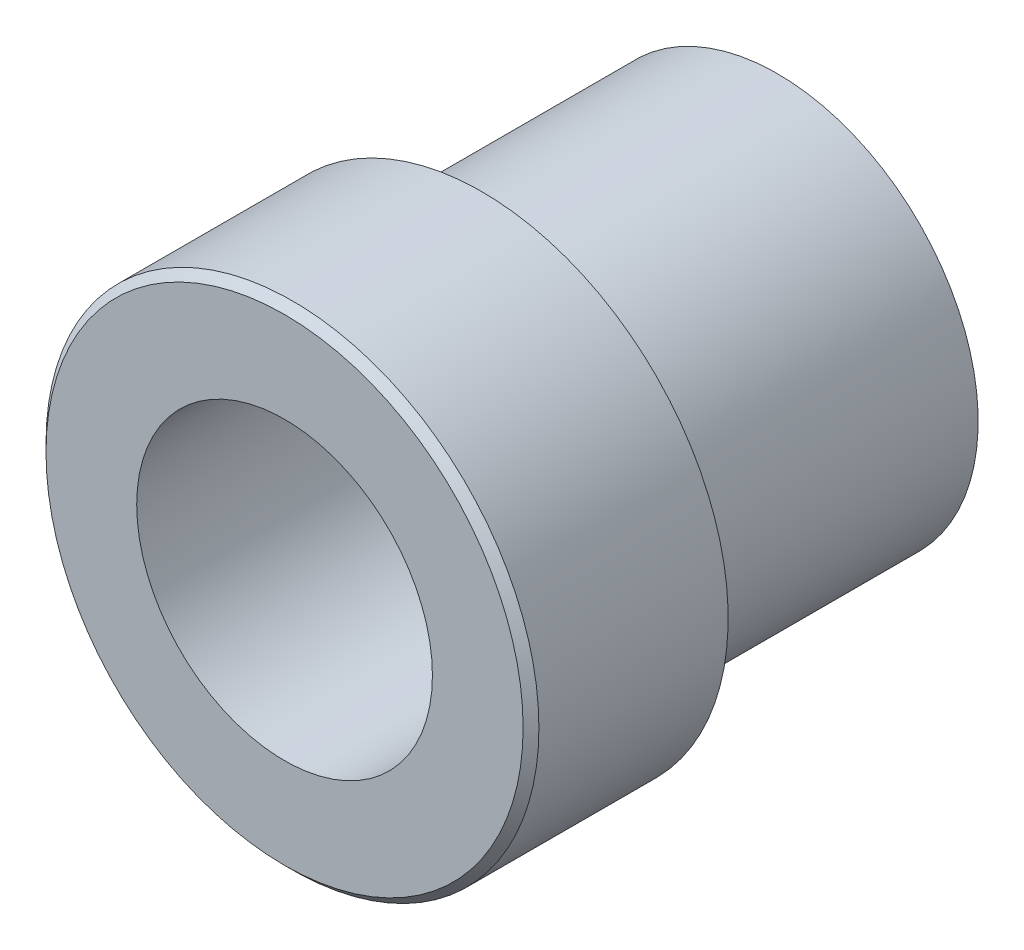
from build123d import *

# Parameters (mm, degrees)
SKETCH1_R                   = 7.9375
BOSS_EXTRUDE1_DEPTH         = 15.875
CHAMFER1_SIZE               = 0.254
SKETCH2_OUTSIDE_W           = 23.376
SKETCH2_OUTSIDE_H           = 23.376
SKETCH2_OUTSIDE_R           = 6.4643
CUT_EXTRUDE1_DEPTH          = 9.525
F_5_16_0_3125_DOWEL_HOLE1_D = 9.525


with BuildPart() as part:
    # Sketch1 → Boss-Extrude1 (new body)
    with BuildSketch(Plane.XY):
        Circle(SKETCH1_R)
    extrude(amount=BOSS_EXTRUDE1_DEPTH)

    # Chamfer1
    chamfer1_edges = [part.edges().sort_by_distance(p)[0] for p in [
        (-7.9375, 0, 15.875),
    ]]
    chamfer(chamfer1_edges, length=CHAMFER1_SIZE)

    # Sketch2 outside → Cut-Extrude1 (cut)
    with BuildSketch(Plane(origin=(0, 0, 0), x_dir=(-1, 0, 0), z_dir=(0, 0, -1))):
        Rectangle(SKETCH2_OUTSIDE_W, SKETCH2_OUTSIDE_H)
        Circle(SKETCH2_OUTSIDE_R, mode=Mode.SUBTRACT)
    extrude(amount=-CUT_EXTRUDE1_DEPTH, mode=Mode.SUBTRACT)

    # 5/16 (0.3125) Dowel Hole1 (through all)
    with Locations(Plane.XY.offset(15.875)):
        with Locations((0, 0)):
            Hole(F_5_16_0_3125_DOWEL_HOLE1_D / 2)


solid = part.part
